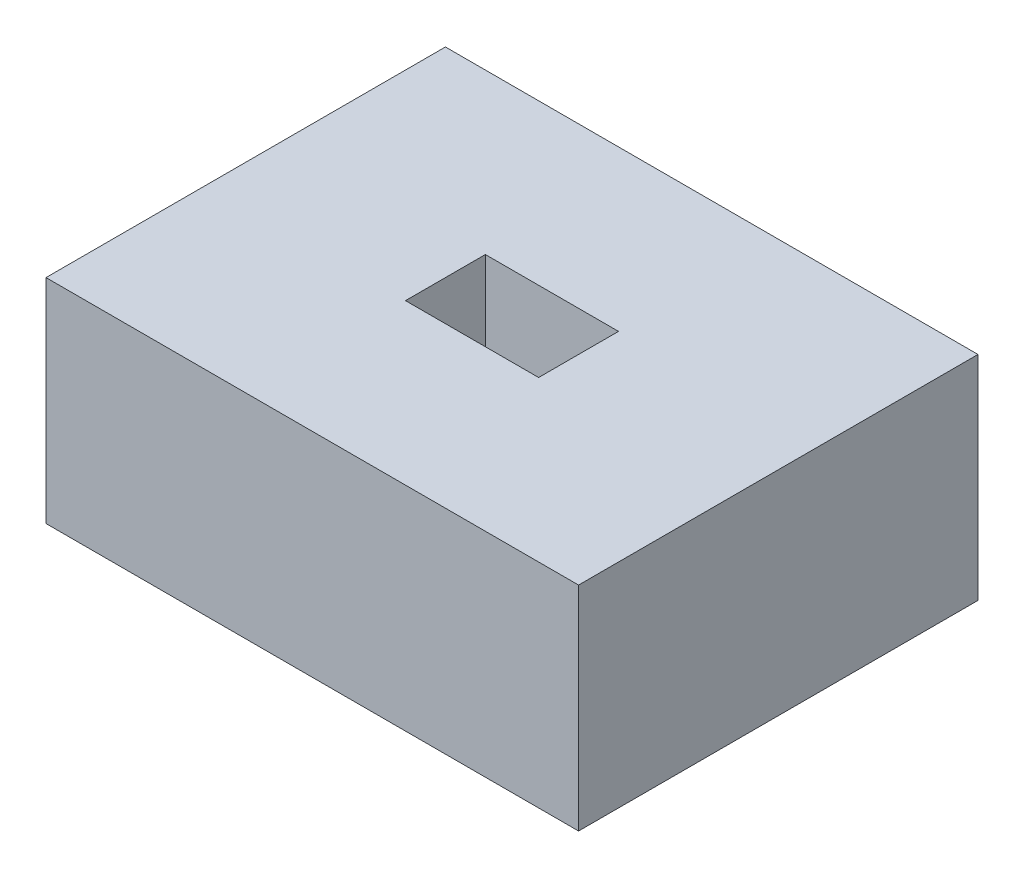
from build123d import *

# Parameters (mm, degrees)
SKETCH1_W           = 20
SKETCH1_H           = 15
BOSS_EXTRUDE1_DEPTH = 8
SKETCH2_W           = 5
SKETCH2_H           = 3
CUT_EXTRUDE1_DEPTH  = 3.2
SKETCH3_W           = 5
SKETCH3_H           = 3
BOSS_EXTRUDE2_DEPTH = 3


with BuildPart() as part:
    # Sketch1 → Boss-Extrude1 (new body)
    with BuildSketch(Plane(origin=(0, 0, 0), x_dir=(1, 0, 0), z_dir=(0, 1, 0))):
        Rectangle(SKETCH1_W, SKETCH1_H)
    extrude(amount=BOSS_EXTRUDE1_DEPTH)

    # Sketch2 → Cut-Extrude1 (cut)
    with BuildSketch(Plane(origin=(0, 8, 0), x_dir=(1, 0, 0), z_dir=(0, 1, 0))):
        Rectangle(SKETCH2_W, SKETCH2_H)
    extrude(amount=-CUT_EXTRUDE1_DEPTH, mode=Mode.SUBTRACT)

    # Sketch3 → Boss-Extrude2 (add)
    with BuildSketch(Plane.XZ):
        Rectangle(SKETCH3_W, SKETCH3_H)
    extrude(amount=BOSS_EXTRUDE2_DEPTH)


solid = part.part
